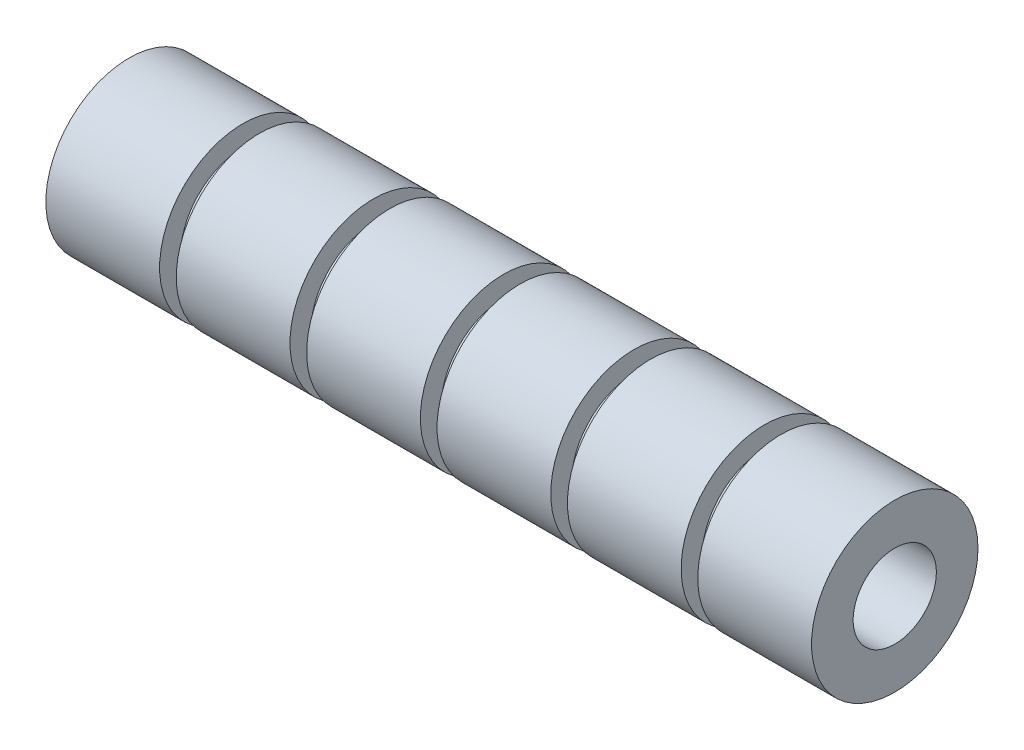
from build123d import *

# Parameters (mm, degrees)
SKETCH_1_R      = 8.5
SKETCH_1_R_2    = 5
EXTRUDE_1_DEPTH = 46
SKETCH_3_W      = 2
SKETCH_3_H      = 1
SKETCH_4_W      = 13.666666667
SKETCH_4_H      = 1.5
SKETCH_4_W_2    = 13.666666666


with BuildPart() as part:
    # 草圖1 → 填料-伸長1 (new body, symmetric)
    with BuildSketch(Plane(origin=(0, 0, 0), x_dir=(0, 0, -1), z_dir=(1, 0, 0))):
        Circle(SKETCH_1_R)
        Circle(SKETCH_1_R_2, mode=Mode.SUBTRACT)
    extrude(amount=EXTRUDE_1_DEPTH, both=True)

    # 草圖3 → 除料-旋轉1 (revolve, cut)
    with BuildSketch(Plane.XY):
        with Locations((31.333333333, 8)):
            Rectangle(SKETCH_3_W, SKETCH_3_H)
        with Locations((15.666666667, 8)):
            Rectangle(SKETCH_3_W, SKETCH_3_H)
        with Locations((0, 8)):
            Rectangle(SKETCH_3_W, SKETCH_3_H)
        with Locations((-15.666666667, 8)):
            Rectangle(SKETCH_3_W, SKETCH_3_H)
        with Locations((-31.333333333, 8)):
            Rectangle(SKETCH_3_W, SKETCH_3_H)
    revolve(axis=Axis((-98.82156335, 0, 0), (1, 0, 0)), mode=Mode.SUBTRACT)

    # 草圖4 → 旋轉2 (revolve)
    with BuildSketch(Plane.XY):
        with Locations((-39.166666666, 9.25)):
            Rectangle(SKETCH_4_W, SKETCH_4_H)
        with Locations((-23.5, 9.25)):
            Rectangle(SKETCH_4_W_2, SKETCH_4_H)
        with Locations((-7.833333334, 9.25)):
            Rectangle(SKETCH_4_W, SKETCH_4_H)
        with Locations((7.833333334, 9.25)):
            Rectangle(SKETCH_4_W, SKETCH_4_H)
        with Locations((23.5, 9.25)):
            Rectangle(SKETCH_4_W_2, SKETCH_4_H)
        with Locations((39.166666666, 9.25)):
            Rectangle(SKETCH_4_W, SKETCH_4_H)
    revolve(axis=Axis((58.089826766, 0, 0), (-1, 0, 0)))


solid = part.part
